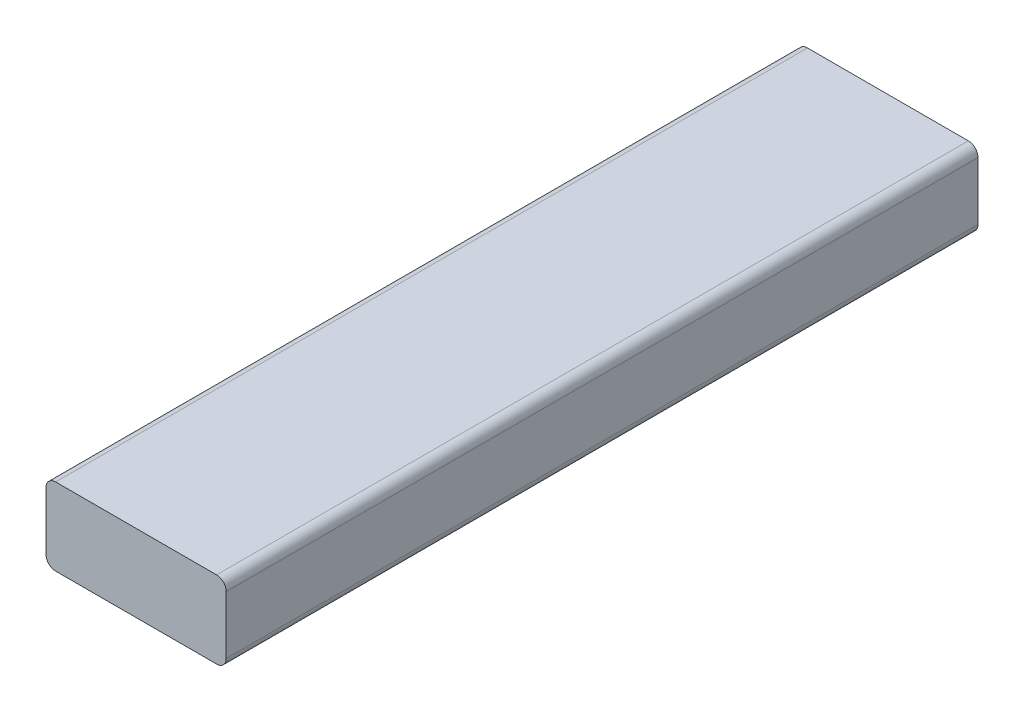
from build123d import *

# Parameters (mm, degrees)
SKETCH1_W           = 88.9
SKETCH1_H           = 38.1
BOSS_EXTRUDE1_DEPTH = 370.7765
FILLET1_R           = 4.7625


with BuildPart() as part:
    # Sketch1 → Boss-Extrude1 (new body)
    with BuildSketch(Plane.XY):
        with Locations((503.382187925, 19.05)):
            Rectangle(SKETCH1_W, SKETCH1_H)
    extrude(amount=BOSS_EXTRUDE1_DEPTH)

    # Fillet1
    fillet1_edges = [part.edges().sort_by_distance(p)[0] for p in [
        (547.832187925, 0, 185.38825),
        (547.832187925, 38.1, 185.38825),
        (458.932187925, 38.1, 185.38825),
        (458.932187925, 0, 185.38825),
    ]]
    fillet(fillet1_edges, radius=FILLET1_R)


solid = part.part
